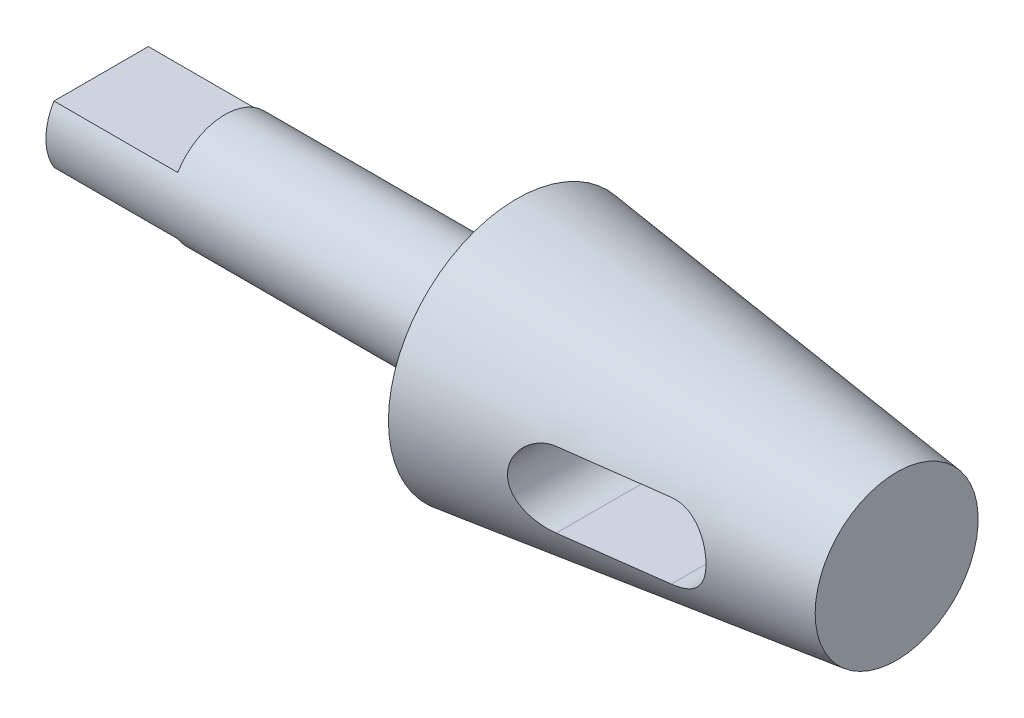
from build123d import *

# Parameters (mm, degrees)
SKETCH_3_W               = 28
SKETCH_3_H               = 6
CUT_EXTRUDE_1_DEPTH      = 30
CUT_EXTRUDE_1_DEPTH_BACK = 30
FILLET_1_R               = 3


with BuildPart() as part:
    # Эскиз2 → Повернуть1 (revolve)
    with BuildSketch(Plane.XY):
        Polygon((-94, 12.5), (0, 12.5), (0, 29), (86, 18.440527762), (86, 0), (-94, 0), align=None)
    revolve(axis=Axis((0, 0, 0), (1, 0, 0)))

    # Эскиз3 → Вырез-Вытянуть1 (cut, two sides)
    with BuildSketch(Plane.XY) as cut_extrude_1_sk:
        with BuildLine():
            Line((32.5, 8.5), (55.5, 8.5))
            ThreePointArc((55.5, 8.5), (64, 0), (55.5, -8.5))
            Line((55.5, -8.5), (32.5, -8.5))
            ThreePointArc((32.5, -8.5), (24, 0), (32.5, 8.5))
        make_face()
        with Locations((-80, -9.5)):
            Rectangle(SKETCH_3_W, SKETCH_3_H)
        with Locations((-80, 9.5)):
            Rectangle(SKETCH_3_W, SKETCH_3_H)
    extrude(amount=CUT_EXTRUDE_1_DEPTH, mode=Mode.SUBTRACT)
    extrude(cut_extrude_1_sk.sketch, amount=-CUT_EXTRUDE_1_DEPTH_BACK, mode=Mode.SUBTRACT)

    # Скругление1
    fillet_1_edges = [part.edges().sort_by_distance(p)[0] for p in [
        (0, -12.5, 0),
    ]]
    fillet(fillet_1_edges, radius=FILLET_1_R)


solid = part.part
